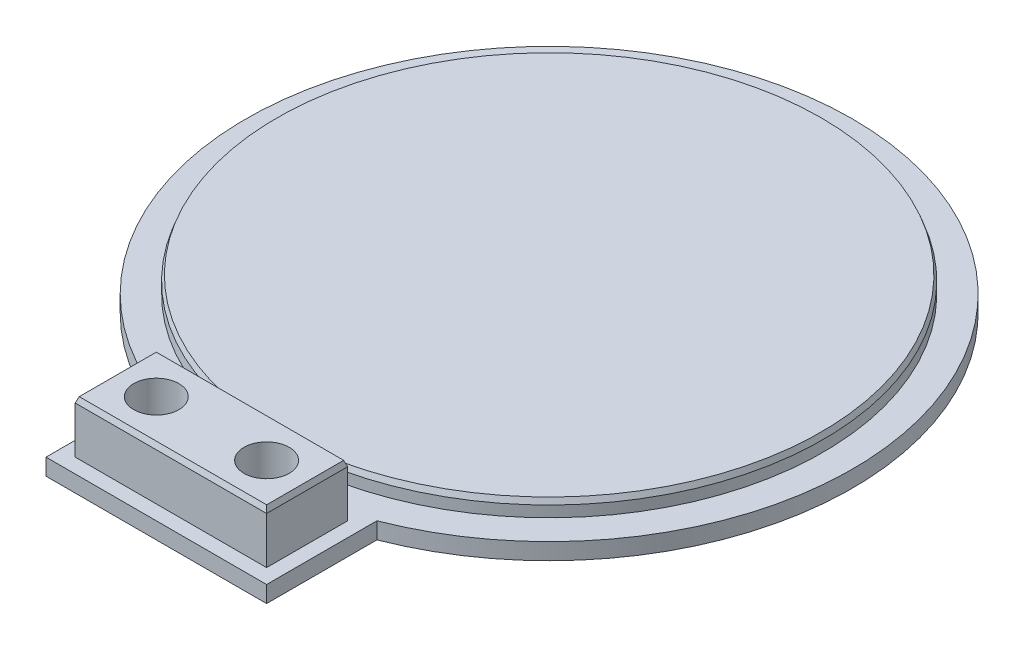
from build123d import *

# Parameters (mm, degrees)
SKETCH1_R             = 55
BOSS_EXTRUDE1_DEPTH   = 3
SKETCH9_W             = 40
SKETCH9_H             = 20
BOSS_EXTRUDE4_DEPTH   = 3
SKETCH11_R            = 4.1
CUT_EXTRUDE6_DEPTH    = 4
SKETCH15_R            = 49.7
BOSS_EXTRUDE6_DEPTH   = 3
CHAMFER2_SIZE         = 1
CHAMFER2_SIZE2        = 0.363970234
SKETCH16_W            = 34.7
SKETCH16_H            = 14.7
SKETCH16_R            = 4.1
BOSS_EXTRUDE7_DEPTH   = 9.5
CHAMFER3_SIZE         = 1
CHAMFER3_SIZE2        = 0.363970234
CHAMFER3_PART_2_SIZE  = 1
CHAMFER3_PART_2_SIZE2 = 0.363970234
CHAMFER3_PART_3_SIZE  = 1
CHAMFER3_PART_3_SIZE2 = 0.363970234
CHAMFER3_PART_4_SIZE  = 1
CHAMFER3_PART_4_SIZE2 = 0.363970234


with BuildPart() as part:
    # Sketch1 → Boss-Extrude1 (new body)
    with BuildSketch(Plane(origin=(0, 0, 0), x_dir=(1, 0, 0), z_dir=(0, 1, 0))):
        with Locations(Location((0, 0, 0), (0, 0, 270))):  # turned: the seam where the file's is
            Circle(SKETCH1_R)
    extrude(amount=BOSS_EXTRUDE1_DEPTH)

    # Sketch9 → Boss-Extrude4 (add)
    with BuildSketch(Plane.XZ):
        with Locations((0, 61.23475383)):
            Rectangle(SKETCH9_W, SKETCH9_H)
    extrude(amount=-BOSS_EXTRUDE4_DEPTH)

    # Sketch11 → Cut-Extrude6 (cut, through all)
    with BuildSketch(Plane(origin=(0, 3, 0), x_dir=(1, 0, 0), z_dir=(0, 1, 0))):
        with Locations(Location((-10, -61.23475383, 0), (0, 0, 270))):  # turned: the seam where the file's is
            Circle(SKETCH11_R)
        with Locations(Location((10, -61.23475383, 0), (0, 0, 270))):  # turned: the seam where the file's is
            Circle(SKETCH11_R)
    extrude(amount=-CUT_EXTRUDE6_DEPTH, mode=Mode.SUBTRACT)

    # Sketch15 → Boss-Extrude6 (add)
    with BuildSketch(Plane(origin=(0, 3, 0), x_dir=(1, 0, 0), z_dir=(0, 1, 0))):
        with Locations(Location((0, 0, 0), (0, 0, 270))):  # turned: the seam where the file's is
            Circle(SKETCH15_R)
    extrude(amount=BOSS_EXTRUDE6_DEPTH)

    # Chamfer2
    chamfer2_edges = [part.edges().sort_by_distance(p)[0] for p in [
        (0, 6, -49.7),
    ]]
    chamfer2_side = [part.faces().sort_by_distance(p)[0] for p in [
        (0, 4.5, -49.7),
    ]]
    chamfer(chamfer2_edges, length=CHAMFER2_SIZE, length2=CHAMFER2_SIZE2, reference=chamfer2_side[0])

    # Sketch16 → Boss-Extrude7 (add)
    with BuildSketch(Plane(origin=(0, 3, 0), x_dir=(1, 0, 0), z_dir=(0, 1, 0))):
        with Locations((0, -61.23475383)):
            Rectangle(SKETCH16_W, SKETCH16_H)
        with Locations(Location((-10, -61.23475383, 0), (0, 0, 270))):  # turned: the seam where the file's is
            Circle(SKETCH16_R, mode=Mode.SUBTRACT)
        with Locations(Location((10, -61.23475383, 0), (0, 0, 270))):  # turned: the seam where the file's is
            Circle(SKETCH16_R, mode=Mode.SUBTRACT)
    extrude(amount=BOSS_EXTRUDE7_DEPTH)

    # Chamfer3
    chamfer3_edges = [part.edges().sort_by_distance(p)[0] for p in [
        (-17.35, 12.5, 61.23475383),
    ]]
    chamfer3_side = [part.faces().sort_by_distance(p)[0] for p in [
        (-17.35, 7.75, 61.23475383),
    ]]
    chamfer(chamfer3_edges, length=CHAMFER3_SIZE, length2=CHAMFER3_SIZE2, reference=chamfer3_side[0])

    # Chamfer3 part 2
    chamfer3_part_2_edges = [part.edges().sort_by_distance(p)[0] for p in [
        (0, 12.5, 68.58475383),
    ]]
    chamfer3_part_2_side = [part.faces().sort_by_distance(p)[0] for p in [
        (0, 7.75, 68.58475383),
    ]]
    chamfer(chamfer3_part_2_edges, length=CHAMFER3_PART_2_SIZE, length2=CHAMFER3_PART_2_SIZE2, reference=chamfer3_part_2_side[0])

    # Chamfer3 part 3
    chamfer3_part_3_edges = [part.edges().sort_by_distance(p)[0] for p in [
        (17.35, 12.5, 61.23475383),
    ]]
    chamfer3_part_3_side = [part.faces().sort_by_distance(p)[0] for p in [
        (17.35, 7.75, 61.23475383),
    ]]
    chamfer(chamfer3_part_3_edges, length=CHAMFER3_PART_3_SIZE, length2=CHAMFER3_PART_3_SIZE2, reference=chamfer3_part_3_side[0])

    # Chamfer3 part 4
    chamfer3_part_4_edges = [part.edges().sort_by_distance(p)[0] for p in [
        (0, 12.5, 53.88475383),
    ]]
    chamfer3_part_4_side = [part.faces().sort_by_distance(p)[0] for p in [
        (0, 7.75, 53.88475383),
    ]]
    chamfer(chamfer3_part_4_edges, length=CHAMFER3_PART_4_SIZE, length2=CHAMFER3_PART_4_SIZE2, reference=chamfer3_part_4_side[0])


solid = part.part
